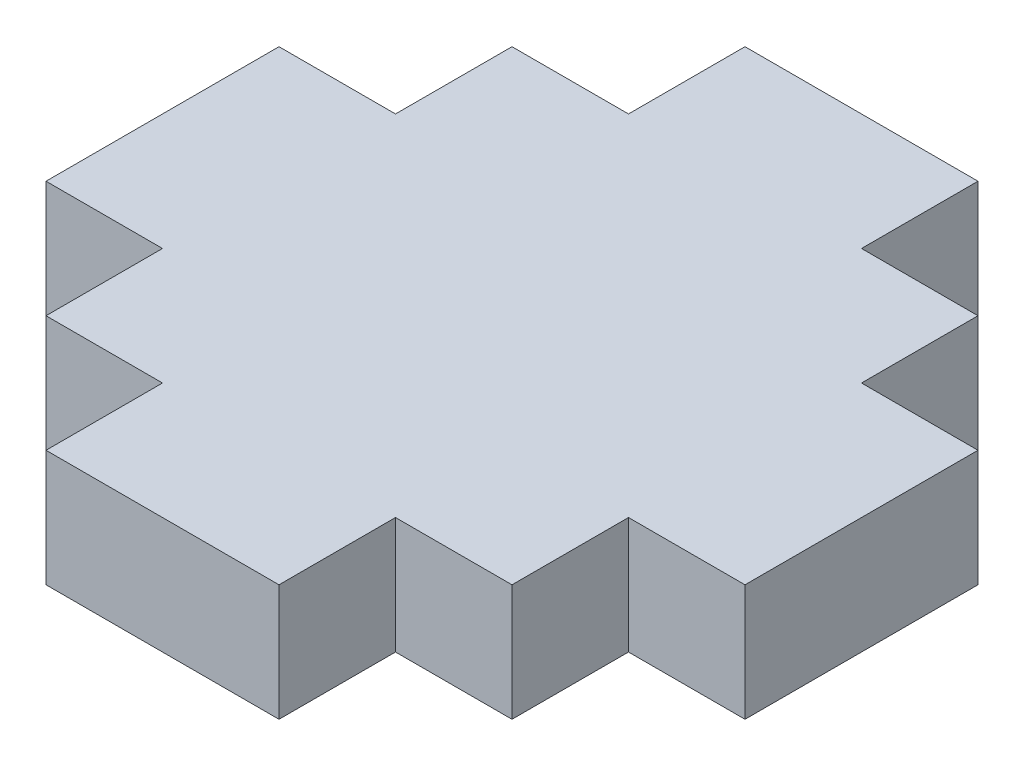
from build123d import *

# Parameters (mm, degrees)
SKETCH1_W           = 12
SKETCH1_H           = 12
BOSS_EXTRUDE1_DEPTH = 1.5
SKETCH2_W           = 6
SKETCH2_H           = 3
SKETCH2_W_2         = 3
SKETCH2_H_2         = 6
BOSS_EXTRUDE2_DEPTH = 1.5


with BuildPart() as part:
    # Sketch1 → Boss-Extrude1 (new body, symmetric)
    with BuildSketch(Plane(origin=(0, 0, 0), x_dir=(1, 0, 0), z_dir=(0, 1, 0))):
        Rectangle(SKETCH1_W, SKETCH1_H)
    extrude(amount=BOSS_EXTRUDE1_DEPTH, both=True)

    # Sketch2 → Boss-Extrude2 (add, symmetric)
    with BuildSketch(Plane(origin=(0, 0, 0), x_dir=(1, 0, 0), z_dir=(0, 1, 0))):
        with Locations((0, 7.5)):
            Rectangle(SKETCH2_W, SKETCH2_H)
        with Locations((0, -7.5)):
            Rectangle(SKETCH2_W, SKETCH2_H)
        with Locations((-7.5, 0)):
            Rectangle(SKETCH2_W_2, SKETCH2_H_2)
        with Locations((7.5, 0)):
            Rectangle(SKETCH2_W_2, SKETCH2_H_2)
    extrude(amount=BOSS_EXTRUDE2_DEPTH, both=True)


solid = part.part
